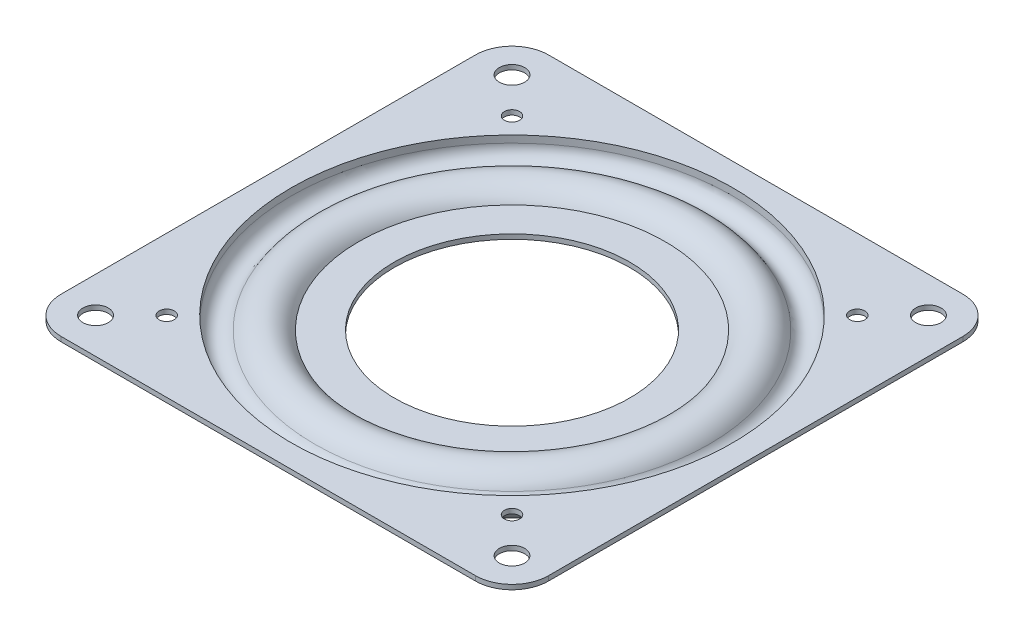
from build123d import *

# Parameters (mm, degrees)
BOSS_EXTRUDE1_START     = -0.7366
SKETCH4_W               = 76.2
SKETCH4_H               = 76.2
SKETCH4_R               = 34.517709056
BOSS_EXTRUDE1_DEPTH     = 0.7366
SKETCH6_R               = 1.984375
SKETCH6_R_2             = 1.190625
CUT_EXTRUDE1_DEPTH      = 4.9370001
CUT_EXTRUDE1_DEPTH_BACK = 1
CIRPATTERN1_COUNT       = 22
FILLET1_R               = 5.715


with BuildPart() as part:
    # Sketch3_3 → Revolve-Thin2 (revolve)
    with BuildSketch(Plane.XY):
        with BuildLine():
            Line((38.1, 3.937), (34.517709056, 3.937))
            Line((34.517709056, 3.937), (34.517709056, 2.83464))
            ThreePointArc((34.517709056, 2.83464), (33.036848091, 0.927495427), (30.822306037, 1.88976))
            ThreePointArc((30.822306037, 1.88976), (27.397571759, 3.936892662), (23.942978742, 1.94056))
            Line((23.942978742, 1.94056), (18.40865, 1.94056))
            Line((18.40865, 1.94056), (18.40865, 1.20396))
            Line((18.40865, 1.20396), (24.403193864, 1.20396))
            ThreePointArc((24.403193864, 1.20396), (27.184620861, 3.195113241), (30.176110069, 1.536192))
            ThreePointArc((30.176110069, 1.536192), (33.219319472, 0.213854232), (35.254309056, 2.83464))
            Line((35.254309056, 2.83464), (35.254309056, 3.2004))
            Line((35.254309056, 3.2004), (38.1, 3.2004))
            Line((38.1, 3.2004), (38.1, 3.937))
        make_face()
    revolve(axis=Axis((0, 3.937, 0), (0, -1, 0)))

    # Sketch4 → Boss-Extrude1 (add)
    with BuildSketch(Plane(origin=(0, 3.937, 0), x_dir=(1, 0, 0), z_dir=(0, 1, 0)).offset(BOSS_EXTRUDE1_START)):
        Rectangle(SKETCH4_W, SKETCH4_H)
        Circle(SKETCH4_R, mode=Mode.SUBTRACT)
    extrude(amount=BOSS_EXTRUDE1_DEPTH)

    # Sketch6 → Cut-Extrude1 (cut, two sides)
    with BuildSketch(Plane(origin=(0, 0, 0), x_dir=(1, 0, 0), z_dir=(0, 1, 0))) as cut_extrude1_sk:
        with Locations((-32.54375, 32.54375)):
            Circle(SKETCH6_R)
        with Locations((-32.54375, -32.54375)):
            Circle(SKETCH6_R)
        with Locations((32.54375, -32.54375)):
            Circle(SKETCH6_R)
        with Locations((32.54375, 32.54375)):
            Circle(SKETCH6_R)
        with Locations((26.9875, 26.9875)):
            Circle(SKETCH6_R_2)
        with Locations((-26.9875, 26.9875)):
            Circle(SKETCH6_R_2)
        with Locations((26.9875, -26.9875)):
            Circle(SKETCH6_R_2)
        with Locations((-26.9875, -26.9875)):
            Circle(SKETCH6_R_2)
    extrude(amount=CUT_EXTRUDE1_DEPTH, mode=Mode.SUBTRACT)
    extrude(cut_extrude1_sk.sketch, amount=-CUT_EXTRUDE1_DEPTH_BACK, mode=Mode.SUBTRACT)

    # Fillet1
    fillet1_edges = [part.edges().sort_by_distance(p)[0] for p in [
        (-38.1, 3.5687, 38.1),
        (-38.1, 3.5687, -38.1),
        (38.1, 3.5687, -38.1),
        (38.1, 3.5687, 38.1),
    ]]
    fillet(fillet1_edges, radius=FILLET1_R)


with BuildPart() as body_2:
    # Sketch8 → Revolve1 (revolve)
    with BuildSketch(Plane.XY):
        with BuildLine():
            Line((27.3685, 3.683), (27.3685, -3.683))
            ThreePointArc((27.3685, -3.683), (31.0515, 0), (27.3685, 3.683))
        make_face()
    revolve(axis=Axis((27.3685, 3.683, 0), (0, -1, 0)))


with BuildPart() as cirpattern1_1:
    # CirPattern1: pattern copy
    add(body_2.part.rotate(Axis((0, 0, 0), (0, 1, 0)), 1 * 360 / CIRPATTERN1_COUNT))


with BuildPart() as cirpattern1_2:
    # CirPattern1: pattern copy
    add(body_2.part.rotate(Axis((0, 0, 0), (0, 1, 0)), 2 * 360 / CIRPATTERN1_COUNT))


with BuildPart() as cirpattern1_3:
    # CirPattern1: pattern copy
    add(body_2.part.rotate(Axis((0, 0, 0), (0, 1, 0)), 3 * 360 / CIRPATTERN1_COUNT))


with BuildPart() as cirpattern1_4:
    # CirPattern1: pattern copy
    add(body_2.part.rotate(Axis((0, 0, 0), (0, 1, 0)), 4 * 360 / CIRPATTERN1_COUNT))


with BuildPart() as cirpattern1_5:
    # CirPattern1: pattern copy
    add(body_2.part.rotate(Axis((0, 0, 0), (0, 1, 0)), 5 * 360 / CIRPATTERN1_COUNT))


with BuildPart() as cirpattern1_6:
    # CirPattern1: pattern copy
    add(body_2.part.rotate(Axis((0, 0, 0), (0, 1, 0)), 6 * 360 / CIRPATTERN1_COUNT))


with BuildPart() as cirpattern1_7:
    # CirPattern1: pattern copy
    add(body_2.part.rotate(Axis((0, 0, 0), (0, 1, 0)), 7 * 360 / CIRPATTERN1_COUNT))


with BuildPart() as cirpattern1_8:
    # CirPattern1: pattern copy
    add(body_2.part.rotate(Axis((0, 0, 0), (0, 1, 0)), 8 * 360 / CIRPATTERN1_COUNT))


with BuildPart() as cirpattern1_9:
    # CirPattern1: pattern copy
    add(body_2.part.rotate(Axis((0, 0, 0), (0, 1, 0)), 9 * 360 / CIRPATTERN1_COUNT))


with BuildPart() as cirpattern1_10:
    # CirPattern1: pattern copy
    add(body_2.part.rotate(Axis((0, 0, 0), (0, 1, 0)), 10 * 360 / CIRPATTERN1_COUNT))


with BuildPart() as cirpattern1_11:
    # CirPattern1: pattern copy
    add(body_2.part.rotate(Axis((0, 0, 0), (0, 1, 0)), 11 * 360 / CIRPATTERN1_COUNT))


with BuildPart() as cirpattern1_12:
    # CirPattern1: pattern copy
    add(body_2.part.rotate(Axis((0, 0, 0), (0, 1, 0)), 12 * 360 / CIRPATTERN1_COUNT))


with BuildPart() as cirpattern1_13:
    # CirPattern1: pattern copy
    add(body_2.part.rotate(Axis((0, 0, 0), (0, 1, 0)), 13 * 360 / CIRPATTERN1_COUNT))


with BuildPart() as cirpattern1_14:
    # CirPattern1: pattern copy
    add(body_2.part.rotate(Axis((0, 0, 0), (0, 1, 0)), 14 * 360 / CIRPATTERN1_COUNT))


with BuildPart() as cirpattern1_15:
    # CirPattern1: pattern copy
    add(body_2.part.rotate(Axis((0, 0, 0), (0, 1, 0)), 15 * 360 / CIRPATTERN1_COUNT))


with BuildPart() as cirpattern1_16:
    # CirPattern1: pattern copy
    add(body_2.part.rotate(Axis((0, 0, 0), (0, 1, 0)), 16 * 360 / CIRPATTERN1_COUNT))


with BuildPart() as cirpattern1_17:
    # CirPattern1: pattern copy
    add(body_2.part.rotate(Axis((0, 0, 0), (0, 1, 0)), 17 * 360 / CIRPATTERN1_COUNT))


with BuildPart() as cirpattern1_18:
    # CirPattern1: pattern copy
    add(body_2.part.rotate(Axis((0, 0, 0), (0, 1, 0)), 18 * 360 / CIRPATTERN1_COUNT))


with BuildPart() as cirpattern1_19:
    # CirPattern1: pattern copy
    add(body_2.part.rotate(Axis((0, 0, 0), (0, 1, 0)), 19 * 360 / CIRPATTERN1_COUNT))


with BuildPart() as cirpattern1_20:
    # CirPattern1: pattern copy
    add(body_2.part.rotate(Axis((0, 0, 0), (0, 1, 0)), 20 * 360 / CIRPATTERN1_COUNT))


with BuildPart() as cirpattern1_21:
    # CirPattern1: pattern copy
    add(body_2.part.rotate(Axis((0, 0, 0), (0, 1, 0)), 21 * 360 / CIRPATTERN1_COUNT))


solid = Compound([part.part, body_2.part, cirpattern1_1.part, cirpattern1_2.part, cirpattern1_3.part, cirpattern1_4.part, cirpattern1_5.part, cirpattern1_6.part, cirpattern1_7.part, cirpattern1_8.part, cirpattern1_9.part, cirpattern1_10.part, cirpattern1_11.part, cirpattern1_12.part, cirpattern1_13.part, cirpattern1_14.part, cirpattern1_15.part, cirpattern1_16.part, cirpattern1_17.part, cirpattern1_18.part, cirpattern1_19.part, cirpattern1_20.part, cirpattern1_21.part])
